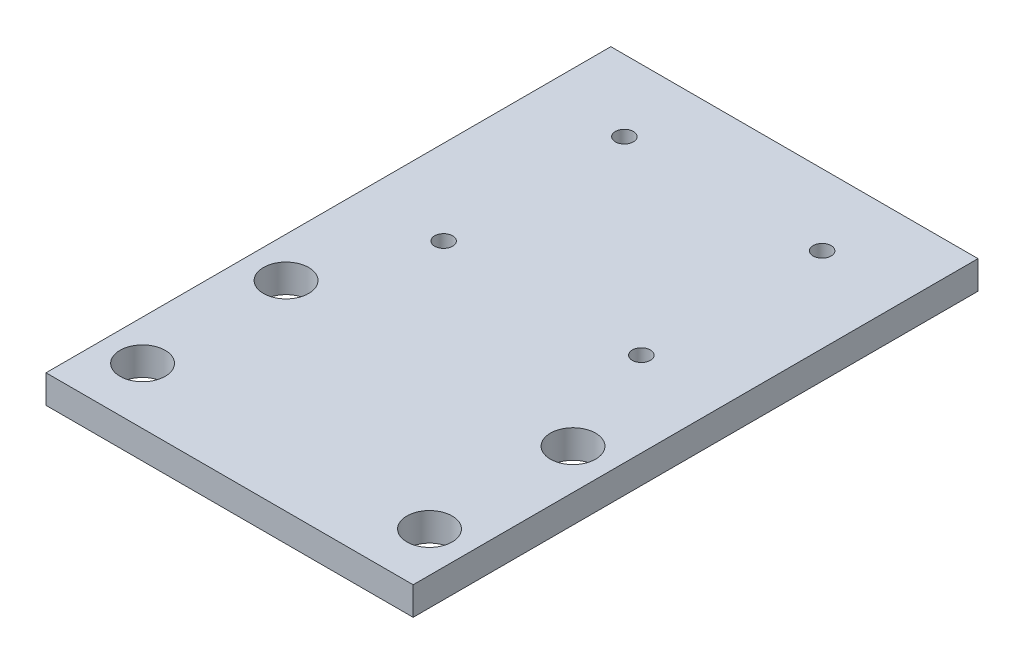
from build123d import *

# Parameters (mm, degrees)
SKETCH1_W           = 65
SKETCH1_H           = 100
SKETCH1_R           = 4
SKETCH1_R_2         = 1.6
BOSS_EXTRUDE1_DEPTH = 5
SKETCH3_R           = 3.5
CUT_EXTRUDE1_DEPTH  = 2


with BuildPart() as part:
    # Sketch1 → Boss-Extrude1 (new body)
    with BuildSketch(Plane(origin=(0, 0, 0), x_dir=(1, 0, 0), z_dir=(0, 1, 0))):
        Rectangle(SKETCH1_W, SKETCH1_H)
        with Locations((-25.4, -40)):
            Circle(SKETCH1_R, mode=Mode.SUBTRACT)
        with Locations((25.4, -40)):
            Circle(SKETCH1_R, mode=Mode.SUBTRACT)
        with Locations((25.4, -14.6)):
            Circle(SKETCH1_R, mode=Mode.SUBTRACT)
        with Locations((-25.4, -14.6)):
            Circle(SKETCH1_R, mode=Mode.SUBTRACT)
        with Locations((-17.5, 5.4)):
            Circle(SKETCH1_R_2, mode=Mode.SUBTRACT)
        with Locations((17.5, 37.4)):
            Circle(SKETCH1_R_2, mode=Mode.SUBTRACT)
        with Locations((-17.5, 37.4)):
            Circle(SKETCH1_R_2, mode=Mode.SUBTRACT)
        with Locations((17.5, 5.4)):
            Circle(SKETCH1_R_2, mode=Mode.SUBTRACT)
    extrude(amount=BOSS_EXTRUDE1_DEPTH)

    # Sketch3 → Cut-Extrude1 (cut)
    with BuildSketch(Plane.XZ):
        with Locations((-17.5, -5.4)):
            Circle(SKETCH3_R)
        with Locations((17.5, -5.4)):
            Circle(SKETCH3_R)
        with Locations((-17.5, -37.4)):
            Circle(SKETCH3_R)
        with Locations((17.5, -37.4)):
            Circle(SKETCH3_R)
    extrude(amount=-CUT_EXTRUDE1_DEPTH, mode=Mode.SUBTRACT)


solid = part.part
